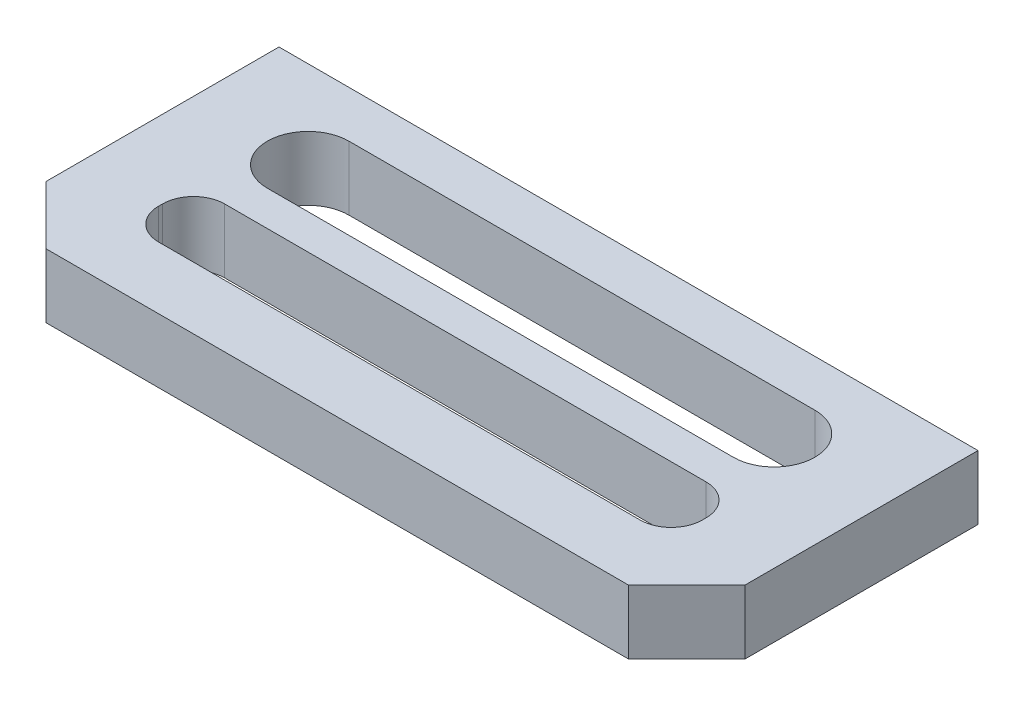
from build123d import *

# Parameters (mm, degrees)
SKIZZE1_W                       = 18
SKIZZE1_H                       = 7.5
SKIZZE1_W_2                     = 14
SKIZZE1_H_2                     = 1.7
AUFSATZ_LINEAR_AUSTRAGEN1_DEPTH = 0.825
VERRUNDUNG1_R                   = 0.8
FASE1_SIZE                      = 1.5


with BuildPart() as part:
    # Skizze1 → Aufsatz-Linear austragen1 (new body, symmetric)
    with BuildSketch(Plane(origin=(0, 0, 0), x_dir=(1, 0, 0), z_dir=(0, 1, 0))):
        Rectangle(SKIZZE1_W, SKIZZE1_H)
        with Locations((0, -1.3)):
            Rectangle(SKIZZE1_W_2, SKIZZE1_H_2, mode=Mode.SUBTRACT)
        with BuildLine():
            Line((-6, 2.55), (6, 2.55))
            ThreePointArc((6, 2.55), (7.05, 1.5), (6, 0.45))
            Line((6, 0.45), (-6, 0.45))
            ThreePointArc((-6, 0.45), (-7.05, 1.5), (-6, 2.55))
        make_face(mode=Mode.SUBTRACT)
    extrude(amount=AUFSATZ_LINEAR_AUSTRAGEN1_DEPTH, both=True)

    # Verrundung1
    verrundung1_edges = [part.edges().sort_by_distance(p)[0] for p in [
        (-7, 0, 2.15),
        (-7, 0, 0.45),
        (7, 0, 0.45),
        (7, 0, 2.15),
    ]]
    fillet(verrundung1_edges, radius=VERRUNDUNG1_R)

    # Fase1
    fase1_edges = [part.edges().sort_by_distance(p)[0] for p in [
        (9, 0, 3.75),
        (-9, 0, 3.75),
    ]]
    chamfer(fase1_edges, length=FASE1_SIZE)


solid = part.part
